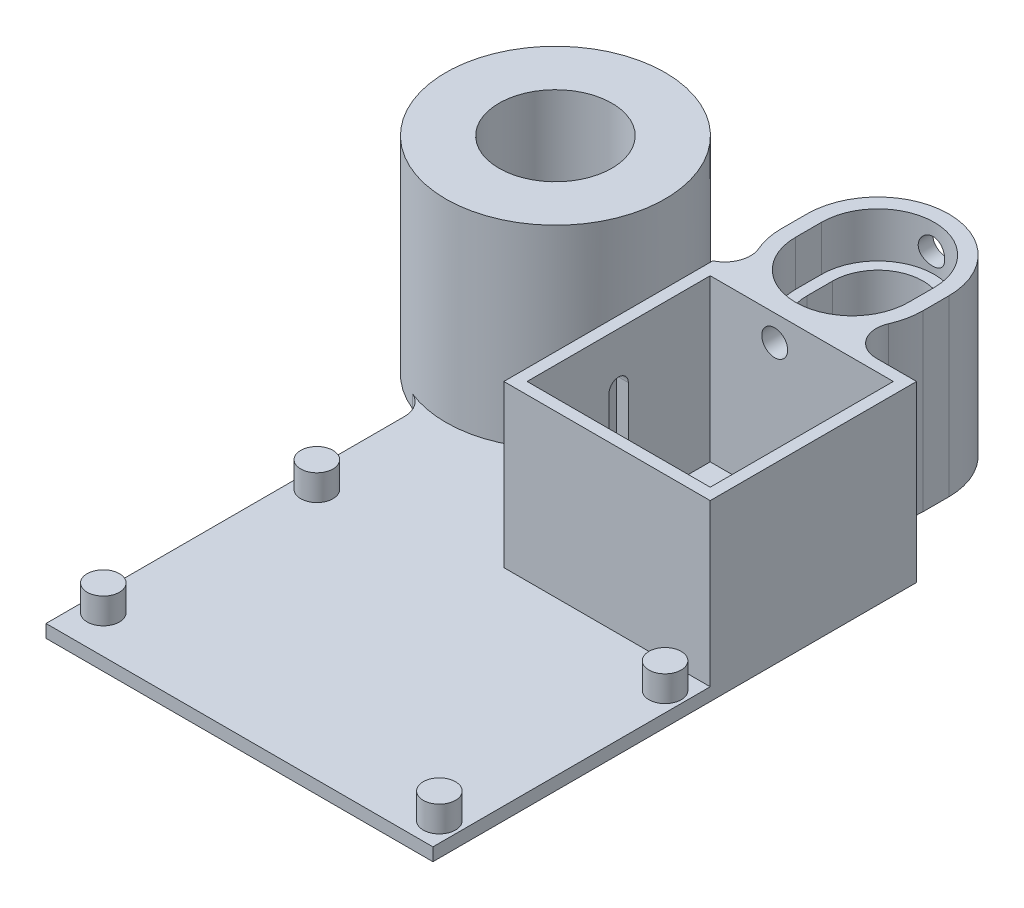
from build123d import *

# Parameters (mm, degrees)
SKETCH1_W                = 76.2
SKETCH1_H                = 95.25
BOSS_EXTRUDE1_DEPTH      = 2.54
SKETCH2_W                = 40.64
SKETCH2_H                = 40.64
BOSS_EXTRUDE2_DEPTH      = 31.75
SKETCH3_W                = 36.068
SKETCH3_H                = 36.068
CUT_EXTRUDE1_DEPTH       = 31.75
SKETCH4_R                = 3.175
BOSS_EXTRUDE3_DEPTH      = 5.08
CUT_EXTRUDE2_REACH       = 42.64
BOSS_EXTRUDE4_DEPTH      = 31.75
BOSS_EXTRUDE4_DEPTH_BACK = 2.54
FILLET1_R                = 5.08
CUT_EXTRUDE3_DEPTH       = 31.75
CUT_EXTRUDE4_DEPTH       = 8.89
SKETCH9_R                = 21.59
BOSS_EXTRUDE5_DEPTH      = 38.1
BOSS_EXTRUDE5_DEPTH_BACK = 2.54
SKETCH10_R               = 11.1125
CUT_EXTRUDE5_DEPTH       = 38.1
CUT_EXTRUDE6_REACH       = 4.54
SKETCH11_R               = 3.175
FILLET2_R                = 5.08
SKETCH13_R               = 2.5527
CUT_EXTRUDE7_DEPTH       = 35.036


with BuildPart() as part:
    # Sketch1 → Boss-Extrude1 (new body)
    with BuildSketch(Plane(origin=(0, 0, 0), x_dir=(1, 0, 0), z_dir=(0, 1, 0))):
        Rectangle(SKETCH1_W, SKETCH1_H)
    extrude(amount=BOSS_EXTRUDE1_DEPTH)

    # Sketch2 → Boss-Extrude2 (add)
    with BuildSketch(Plane(origin=(0, 2.54, 0), x_dir=(1, 0, 0), z_dir=(0, 1, 0))):
        with Locations((17.78, 27.305)):
            Rectangle(SKETCH2_W, SKETCH2_H)
    extrude(amount=BOSS_EXTRUDE2_DEPTH)

    # Sketch3 → Cut-Extrude1 (cut)
    with BuildSketch(Plane(origin=(0, 34.29, 0), x_dir=(1, 0, 0), z_dir=(0, 1, 0))):
        with Locations((17.78, 27.305)):
            Rectangle(SKETCH3_W, SKETCH3_H)
    extrude(amount=-CUT_EXTRUDE1_DEPTH, mode=Mode.SUBTRACT)

    # Sketch4 → Boss-Extrude3 (add)
    with BuildSketch(Plane(origin=(0, 2.54, 0), x_dir=(1, 0, 0), z_dir=(0, 1, 0))):
        with Locations(Location((34.29, 1.905, 0), (0, 0, 90))):  # turned: the seam where the file's is
            Circle(SKETCH4_R)
        with Locations(Location((34.29, -42.545, 0), (0, 0, 90))):  # turned: the seam where the file's is
            Circle(SKETCH4_R)
        with Locations(Location((-34.29, 1.905, 0), (0, 0, 90))):  # turned: the seam where the file's is
            Circle(SKETCH4_R)
        with Locations(Location((-34.29, -40.148547917, 0), (0, 0, 90))):  # turned: the seam where the file's is
            Circle(SKETCH4_R)
    extrude(amount=BOSS_EXTRUDE3_DEPTH)

    # Sketch5 → Cut-Extrude2 (cut, up to next)
    with BuildSketch(Plane.ZY.offset(2.54), mode=Mode.PRIVATE) as cut_extrude2_sk1:
        with BuildLine():
            Line((-29.21, 24.13), (-29.21, 5.08))
            ThreePointArc((-29.21, 5.08), (-27.305, 3.175), (-25.4, 5.08))
            Line((-25.4, 5.08), (-25.4, 24.13))
            ThreePointArc((-25.4, 24.13), (-27.305, 26.035), (-29.21, 24.13))
        make_face()
    cut_extrude2_tool1 = extrude(cut_extrude2_sk1.sketch, amount=-CUT_EXTRUDE2_REACH, mode=Mode.PRIVATE) & part.part
    add(cut_extrude2_tool1.solids().sort_by_distance((-2.54, 14.605, -27.305))[0], mode=Mode.SUBTRACT)

    # Sketch6 → Boss-Extrude4 (add, two sides)
    with BuildSketch(Plane(origin=(0, 2.54, 0), x_dir=(1, 0, 0), z_dir=(0, 1, 0))) as boss_extrude4_sk:
        with BuildLine():
            Line((26.67, 60.325), (26.67, 65.405))
            ThreePointArc((26.67, 65.405), (12.7, 79.375), (-1.27, 65.405))
            Line((-1.27, 65.405), (-1.27, 60.325))
            ThreePointArc((-1.27, 60.325), (12.7, 46.355), (26.67, 60.325))
        make_face()
    extrude(amount=BOSS_EXTRUDE4_DEPTH)
    extrude(boss_extrude4_sk.sketch, amount=-BOSS_EXTRUDE4_DEPTH_BACK)

    # Fillet1
    fillet1_edges = [part.edges().sort_by_distance(p)[0] for p in [
        (18.519871133, 17.145, -47.625),
        (6.880128867, 17.145, -47.625),
    ]]
    fillet(fillet1_edges, radius=FILLET1_R)

    # Sketch7 → Cut-Extrude3 (cut)
    with BuildSketch(Plane(origin=(0, 34.29, 0), x_dir=(1, 0, 0), z_dir=(0, 1, 0))):
        with BuildLine():
            Line((21.59, 60.325), (21.59, 65.405))
            ThreePointArc((21.59, 65.405), (12.7, 74.295), (3.81, 65.405))
            Line((3.81, 65.405), (3.81, 60.325))
            ThreePointArc((3.81, 60.325), (12.7, 51.435), (21.59, 60.325))
        make_face()
    extrude(amount=-CUT_EXTRUDE3_DEPTH, mode=Mode.SUBTRACT)

    # Sketch8 → Cut-Extrude4 (cut)
    with BuildSketch(Plane(origin=(0, 34.29, 0), x_dir=(1, 0, 0), z_dir=(0, 1, 0))):
        with BuildLine():
            Line((23.8125, 60.325), (23.8125, 65.405))
            ThreePointArc((23.8125, 65.405), (12.7, 76.5175), (1.5875, 65.405))
            Line((1.5875, 65.405), (1.5875, 60.325))
            ThreePointArc((1.5875, 60.325), (12.7, 49.2125), (23.8125, 60.325))
        make_face()
    extrude(amount=-CUT_EXTRUDE4_DEPTH, mode=Mode.SUBTRACT)

    # Sketch9 → Boss-Extrude5 (add, two sides)
    with BuildSketch(Plane(origin=(0, 2.54, 0), x_dir=(1, 0, 0), z_dir=(0, 1, 0))) as boss_extrude5_sk:
        with Locations(Location((-33.02, 47.625, 0), (0, 0, 270))):  # turned: the seam where the file's is
            Circle(SKETCH9_R)
    extrude(amount=BOSS_EXTRUDE5_DEPTH)
    extrude(boss_extrude5_sk.sketch, amount=-BOSS_EXTRUDE5_DEPTH_BACK)

    # Sketch10 → Cut-Extrude5 (cut)
    with BuildSketch(Plane(origin=(0, 40.64, 0), x_dir=(1, 0, 0), z_dir=(0, 1, 0))):
        with Locations(Location((-33.02, 47.625, 0), (0, 0, 270))):  # turned: the seam where the file's is
            Circle(SKETCH10_R)
    extrude(amount=-CUT_EXTRUDE5_DEPTH, mode=Mode.SUBTRACT)

    # Sketch11 → Cut-Extrude6 (cut, up to next)
    with BuildSketch(Plane(origin=(0, 2.54, 0), x_dir=(1, 0, 0), z_dir=(0, 1, 0)), mode=Mode.PRIVATE) as cut_extrude6_sk1:
        with Locations(Location((12.7, 60.325, 0), (0, 0, 270))):  # turned: the seam where the file's is
            Circle(SKETCH11_R)
    cut_extrude6_tool1 = extrude(cut_extrude6_sk1.sketch, amount=-CUT_EXTRUDE6_REACH, mode=Mode.PRIVATE) & part.part
    add(cut_extrude6_tool1.solids().sort_by_distance((12.7, 2.54, -60.325))[0], mode=Mode.SUBTRACT)
    # Sketch11 → Cut-Extrude6 (cut, up to next)
    with BuildSketch(Plane(origin=(0, 2.54, 0), x_dir=(1, 0, 0), z_dir=(0, 1, 0)), mode=Mode.PRIVATE) as cut_extrude6_sk2:
        with Locations(Location((-33.02, 47.625, 0), (0, 0, 270))):  # turned: the seam where the file's is
            Circle(SKETCH11_R)
    cut_extrude6_tool2 = extrude(cut_extrude6_sk2.sketch, amount=-CUT_EXTRUDE6_REACH, mode=Mode.PRIVATE) & part.part
    add(cut_extrude6_tool2.solids().sort_by_distance((-33.02, 2.54, -47.625))[0], mode=Mode.SUBTRACT)

    # Fillet2
    fillet2_edges = [part.edges().sort_by_distance(p)[0] for p in [
        (-11.43, 1.27, -47.625),
        (-38.1, 1.27, -26.641156215),
    ]]
    fillet(fillet2_edges, radius=FILLET2_R)

    # Sketch13 → Cut-Extrude7 (cut, through all)
    with BuildSketch(Plane.XY.offset(-45.339)):
        with Locations((12.446, 29.21)):
            Circle(SKETCH13_R)
    extrude(amount=-CUT_EXTRUDE7_DEPTH, mode=Mode.SUBTRACT)


solid = part.part
